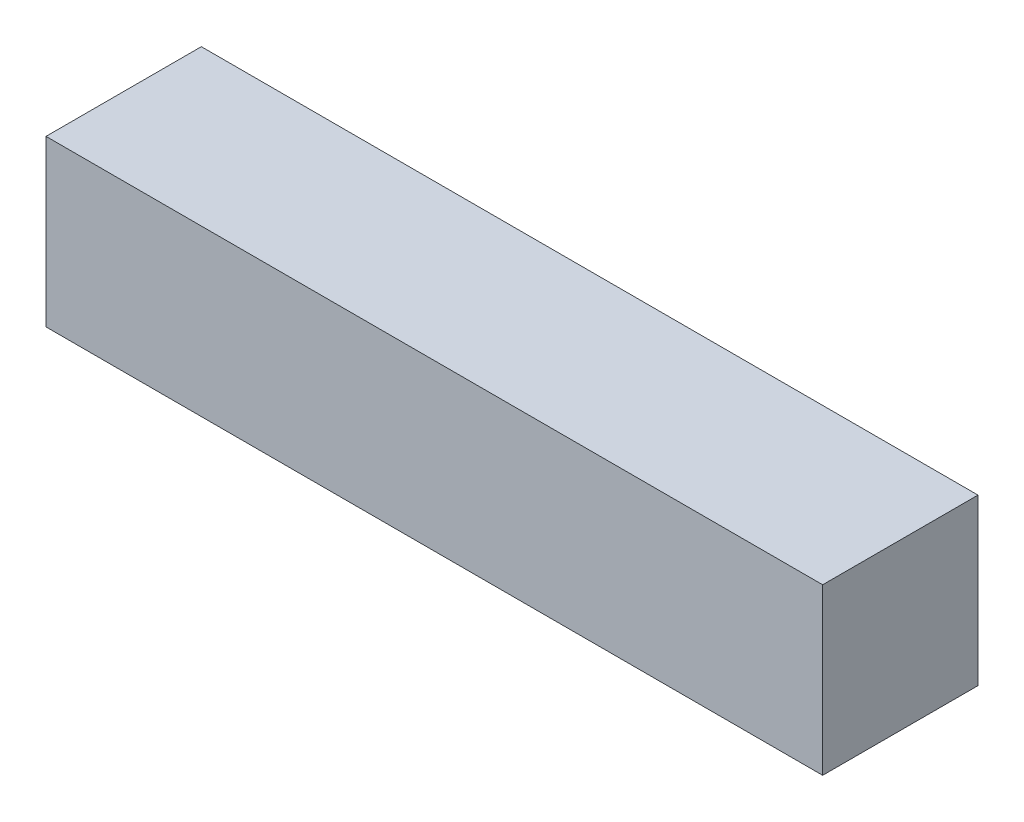
from build123d import *

# Parameters (mm, degrees)
SKETCH1_W           = 12192
SKETCH1_H           = 2438.4
BOSS_EXTRUDE1_DEPTH = 2590.8
SKETCH2_W           = 2336.8
SKETCH2_H           = 2235.2
CUT_EXTRUDE1_DEPTH  = 12039.6


with BuildPart() as part:
    # Sketch1 → Boss-Extrude1 (new body)
    with BuildSketch(Plane(origin=(0, 0, 0), x_dir=(1, 0, 0), z_dir=(0, 1, 0))):
        with Locations((6096, -1219.2)):
            Rectangle(SKETCH1_W, SKETCH1_H)
    extrude(amount=BOSS_EXTRUDE1_DEPTH)

    # Sketch2 → Cut-Extrude1 (cut)
    with BuildSketch(Plane.ZY.offset(-76.2)):
        with Locations((1219.2, 1295.4)):
            Rectangle(SKETCH2_W, SKETCH2_H)
    extrude(amount=-CUT_EXTRUDE1_DEPTH, mode=Mode.SUBTRACT)


solid = part.part
